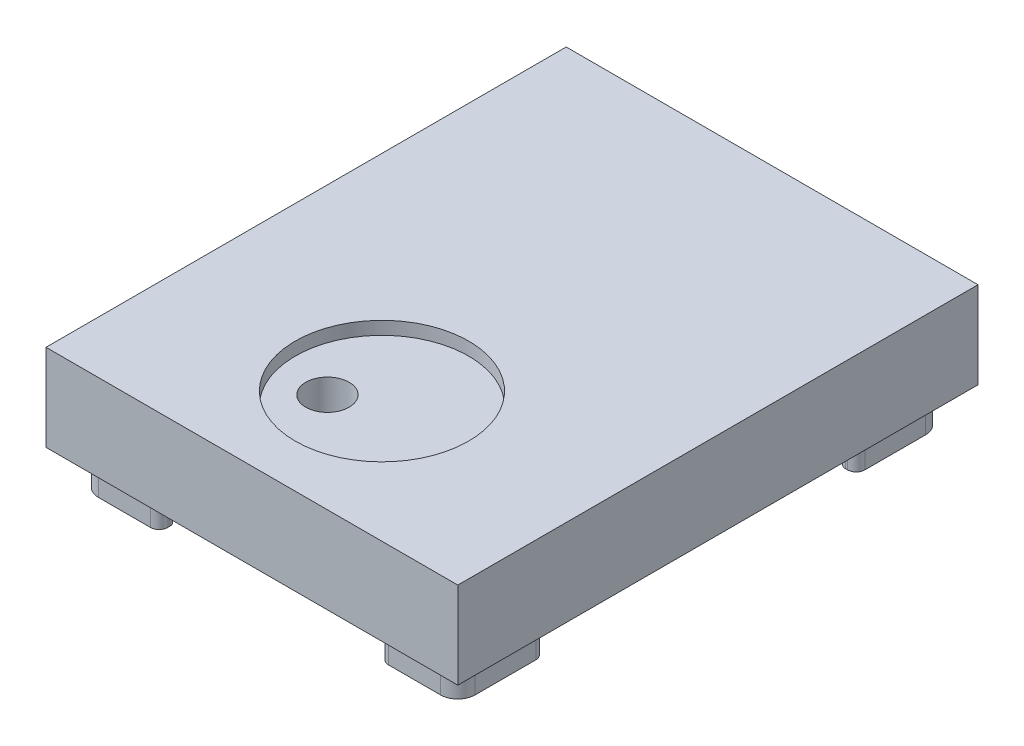
from build123d import *

# Parameters (mm, degrees)
SKETCH2_W                                  = 95
SKETCH2_H                                  = 120
TOP_PLATE_DEPTH                            = 20
FRICTION_CLIP_DEPTH                        = 8
F_4_CLIPS_AT_THE_SECOND_PLANE_COPY_1_DEPTH = 8
CUT_EXTRUDE1_DEPTH                         = 15
SKETCH5_R                                  = 5
SNOOZE_HOLE_DEPTH                          = 29
SKETCH6_R                                  = 8
SKETCH6_R_2                                = 5
SNOOZE_HOLE_SUPPORT_DEPTH                  = 15
SNOOZE_HOLE_SUPPORT_DEPTH_BACK             = 15
SKETCH9_R                                  = 20
LAKE_INLAY_DEPTH                           = 3


with BuildPart() as part:
    # Sketch2 → top plate (new body)
    with BuildSketch(Plane(origin=(0, 0, 0), x_dir=(1, 0, 0), z_dir=(0, 1, 0))):
        Rectangle(SKETCH2_W, SKETCH2_H)
    extrude(amount=TOP_PLATE_DEPTH)

    # Sketch3 → friction clip (add)
    with BuildSketch(Plane.XZ):
        with BuildLine():
            Line((-37.45, 51.95), (-26.95, 51.95))
            ThreePointArc((-26.95, 51.95), (-25.889339828, 52.389339828), (-25.45, 53.45))
            Line((-25.45, 53.45), (-25.45, 53.95))
            ThreePointArc((-25.45, 53.95), (-26.035786438, 55.364213562), (-27.45, 55.95))
            Line((-27.45, 55.95), (-39.45, 55.95))
            ThreePointArc((-39.45, 55.95), (-42.278427125, 54.778427125), (-43.45, 51.95))
            Line((-43.45, 51.95), (-43.45, 37.95))
            ThreePointArc((-43.45, 37.95), (-42.864213562, 36.535786438), (-41.45, 35.95))
            Line((-41.45, 35.95), (-40.95, 35.95))
            ThreePointArc((-40.95, 35.95), (-39.889339828, 36.389339828), (-39.45, 37.45))
            Line((-39.45, 37.45), (-39.45, 49.95))
            ThreePointArc((-39.45, 49.95), (-38.864213562, 51.364213562), (-37.45, 51.95))
        make_face()
    friction_clip = extrude(amount=FRICTION_CLIP_DEPTH)

    # 4 clips: friction clip across plane
    add(friction_clip.mirror(Plane.XY))

    # 4 clips at the second plane: friction clip across plane
    add(friction_clip.mirror(Plane(origin=(0, 0, 0), x_dir=(0, 0, 1), z_dir=(1, 0, 0))))

    # 4 clips at the second plane copy 1 sketc → 4 clips at the second plane copy 1 (add)
    with BuildSketch(Plane(origin=(0, 0, 0), x_dir=(-1, 0, 0), z_dir=(0, -1, 0))):
        with BuildLine():
            Line((-37.45, 51.95), (-26.95, 51.95))
            ThreePointArc((-26.95, 51.95), (-25.889339828, 52.389339828), (-25.45, 53.45))
            Line((-25.45, 53.45), (-25.45, 53.95))
            ThreePointArc((-25.45, 53.95), (-26.035786438, 55.364213562), (-27.45, 55.95))
            Line((-27.45, 55.95), (-39.45, 55.95))
            ThreePointArc((-39.45, 55.95), (-42.278427125, 54.778427125), (-43.45, 51.95))
            Line((-43.45, 51.95), (-43.45, 37.95))
            ThreePointArc((-43.45, 37.95), (-42.864213562, 36.535786438), (-41.45, 35.95))
            Line((-41.45, 35.95), (-40.95, 35.95))
            ThreePointArc((-40.95, 35.95), (-39.889339828, 36.389339828), (-39.45, 37.45))
            Line((-39.45, 37.45), (-39.45, 49.95))
            ThreePointArc((-39.45, 49.95), (-38.864213562, 51.364213562), (-37.45, 51.95))
        make_face()
    extrude(amount=F_4_CLIPS_AT_THE_SECOND_PLANE_COPY_1_DEPTH)

    # Sketch8 → Cut-Extrude1 (cut)
    with BuildSketch(Plane.XZ):
        with BuildLine():
            Line((-36.864213562, -51.364213562), (36.864213562, -51.364213562))
            ThreePointArc((36.864213562, -51.364213562), (38.278427125, -50.778427125), (38.864213562, -49.364213562))
            Line((38.864213562, -49.364213562), (38.864213562, 49.364213562))
            ThreePointArc((38.864213562, 49.364213562), (38.278427125, 50.778427125), (36.864213562, 51.364213562))
            Line((36.864213562, 51.364213562), (-36.864213562, 51.364213562))
            ThreePointArc((-36.864213562, 51.364213562), (-38.278427125, 50.778427125), (-38.864213562, 49.364213562))
            Line((-38.864213562, 49.364213562), (-38.864213562, -49.364213562))
            ThreePointArc((-38.864213562, -49.364213562), (-38.278427125, -50.778427125), (-36.864213562, -51.364213562))
        make_face()
    extrude(amount=-CUT_EXTRUDE1_DEPTH, mode=Mode.SUBTRACT)

    # Sketch5 → snooze hole (cut, through all)
    with BuildSketch(Plane(origin=(0, 20, 0), x_dir=(1, 0, 0), z_dir=(0, 1, 0))):
        with Locations((-8.56, -34.015)):
            Circle(SKETCH5_R)
    extrude(amount=-SNOOZE_HOLE_DEPTH, mode=Mode.SUBTRACT)

    # Sketch6 → snooze hole support (add, two sides)
    with BuildSketch(Plane.XZ) as snooze_hole_support_sk:
        with Locations((-8.56, 34.015)):
            Circle(SKETCH6_R)
        with Locations((-8.56, 34.015)):
            Circle(SKETCH6_R_2, mode=Mode.SUBTRACT)
    extrude(amount=SNOOZE_HOLE_SUPPORT_DEPTH)
    extrude(snooze_hole_support_sk.sketch, amount=-SNOOZE_HOLE_SUPPORT_DEPTH_BACK)

    # Sketch9 → lake inlay (cut)
    with BuildSketch(Plane(origin=(0, 20, 0), x_dir=(1, 0, 0), z_dir=(0, 1, 0))):
        with Locations((0, -30)):
            Circle(SKETCH9_R)
    extrude(amount=-LAKE_INLAY_DEPTH, mode=Mode.SUBTRACT)


solid = part.part
